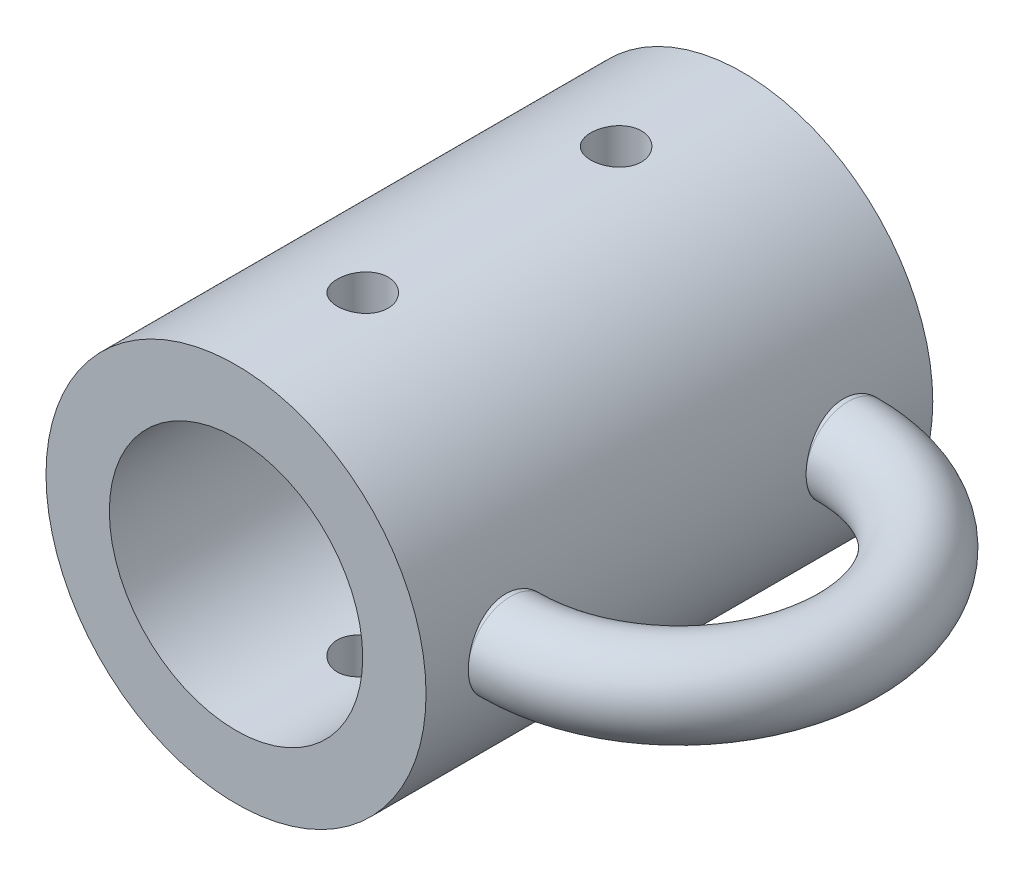
from build123d import *

# Parameters (mm, degrees)
BOSS_EXTRUDE1_DEPTH      = 30
BOSS_EXTRUDE1_DEPTH_BACK = 30
SKETCH1_R                = 22.5
SKETCH1_R_2              = 15
CUT_EXTRUDE1_START       = -50
SKETCH2_R                = 3.000000000000001
CUT_EXTRUDE1_DEPTH       = 80
SKETCH4_R                = 5.000000000000001


with BuildPart() as part:
    # Sketch1 → Boss-Extrude1 (new, two sides: drawn at the far end of the back side and taken through both)
    with BuildSketch(Plane.XY.offset(-BOSS_EXTRUDE1_DEPTH_BACK)):
        Circle(SKETCH1_R)
        Circle(SKETCH1_R_2, mode=Mode.SUBTRACT)
    extrude(amount=BOSS_EXTRUDE1_DEPTH + BOSS_EXTRUDE1_DEPTH_BACK)

    # Sketch2 → Cut-Extrude1 (cut)
    with BuildSketch(Plane(origin=(0, 0, 0), x_dir=(1, 0, 0), z_dir=(0, 1, 0)).offset(CUT_EXTRUDE1_START)):
        with Locations((0, -15)):
            Circle(SKETCH2_R)
    cut_extrude1 = extrude(amount=CUT_EXTRUDE1_DEPTH, mode=Mode.SUBTRACT)

    # Mirror1: Cut-Extrude1 across plane
    add(cut_extrude1.mirror(Plane.XY), mode=Mode.SUBTRACT)

    # Sweep2: sweep along a path in Sketch3
    with BuildLine(Plane(origin=(0, 0, 0), x_dir=(1, 0, 0), z_dir=(0, 1, 0))) as sweep2_path:
        Line((20, -20), (22.500000000000004, -20))
        ThreePointArc((22.500000000000004, -20), (42.50000000000001, 0), (22.500000000000004, 20))
        Line((22.500000000000004, 20), (20.000000000000004, 20))
    # Sketch4 → Sweep2 (sweep)
    with BuildSketch(Plane(origin=(20, 0, 0), x_dir=(0, 0, -1), z_dir=(1, 0, 0))):
        with Locations((-20, 0)):
            Circle(SKETCH4_R)
    sweep(path=sweep2_path.line)


solid = part.part
